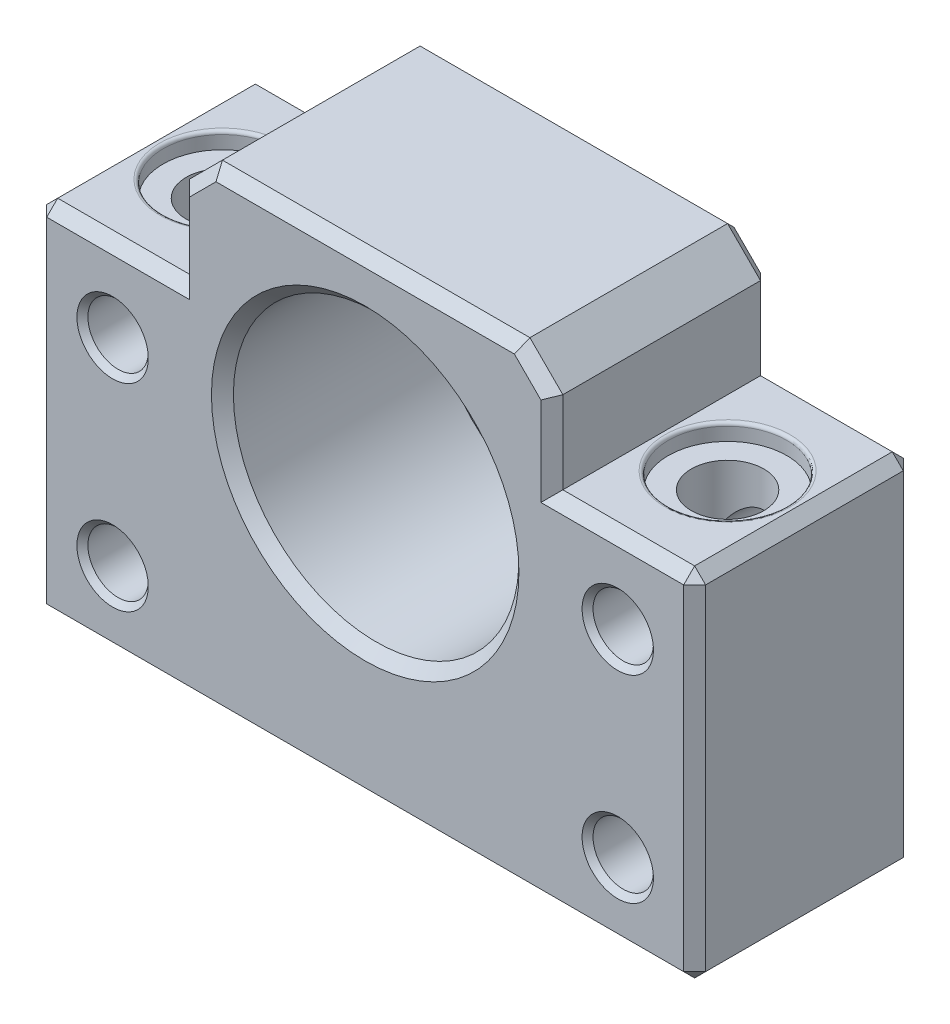
from build123d import *

# Parameters (mm, degrees)
SKETCH1_R           = 13
BOSS_EXTRUDE1_DEPTH = 20
CHAMFER1_SIZE       = 3
CHAMFER2_SIZE       = 1
SKETCH2_R           = 2.75
CUT_EXTRUDE1_DEPTH  = 21
CUT_EXTRUDE2_REACH  = 45
SKETCH3_R           = 3.3
SKETCH4_R           = 5.4
CUT_EXTRUDE3_DEPTH  = 1.5
CHAMFER3_SIZE       = 0.5
FILLET1_R           = 0.3


with BuildPart() as part:
    # Sketch1 → Boss-Extrude1 (new body)
    with BuildSketch(Plane.XY):
        Polygon((17, 0), (-17, 0), (-17, -10.5), (-30, -10.5), (-30, -43), (30, -43), (30, -10.5), (17, -10.5), align=None)
        with Locations((0, -18)):
            Circle(SKETCH1_R, mode=Mode.SUBTRACT)
    extrude(amount=BOSS_EXTRUDE1_DEPTH)

    # Chamfer1
    chamfer1_edges = [part.edges().sort_by_distance(p)[0] for p in [
        (-17, 0, 10),
        (17, 0, 10),
    ]]
    chamfer(chamfer1_edges, length=CHAMFER1_SIZE)

    # Chamfer2
    chamfer2_edges = [part.edges().sort_by_distance(p)[0] for p in [
        (23.5, -10.5, 20),
        (30, -26.75, 0),
        (0, -43, 0),
        (17, -6.75, 20),
        (-30, -43, 10),
        (-30, -10.5, 10),
        (30, -10.5, 10),
        (30, -43, 10),
        (-13, -18, 0),
        (-13, -18, 20),
        (-23.5, -10.5, 20),
        (-30, -26.75, 20),
        (0, 0, 0),
        (0, 0, 20),
        (-17, -6.75, 0),
        (-15.5, -1.5, 0),
        (15.5, -1.5, 0),
        (-17, -6.75, 20),
        (-15.5, -1.5, 20),
        (15.5, -1.5, 20),
        (0, -43, 20),
        (30, -26.75, 20),
        (-30, -26.75, 0),
        (-23.5, -10.5, 0),
        (17, -6.75, 0),
        (23.5, -10.5, 0),
    ]]
    chamfer(chamfer2_edges, length=CHAMFER2_SIZE)

    # Sketch2 → Cut-Extrude1 (cut, through all)
    with BuildSketch(Plane(origin=(0, 0, 0), x_dir=(-1, 0, 0), z_dir=(0, 0, -1))):
        with Locations((-23, -18)):
            Circle(SKETCH2_R)
        with Locations((23, -18)):
            Circle(SKETCH2_R)
        with Locations((23, -36)):
            Circle(SKETCH2_R)
        with Locations((-23, -36)):
            Circle(SKETCH2_R)
    extrude(amount=-CUT_EXTRUDE1_DEPTH, mode=Mode.SUBTRACT)

    # Sketch3 → Cut-Extrude2 (cut, up to next)
    with BuildSketch(Plane.XZ.offset(43), mode=Mode.PRIVATE) as cut_extrude2_sk1:
        with Locations((23, 10)):
            Circle(SKETCH3_R)
    cut_extrude2_tool1 = extrude(cut_extrude2_sk1.sketch, amount=-CUT_EXTRUDE2_REACH, mode=Mode.PRIVATE) & part.part
    add(cut_extrude2_tool1.solids().sort_by_distance((23, -43, 10))[0], mode=Mode.SUBTRACT)
    # Sketch3 → Cut-Extrude2 (cut, up to next)
    with BuildSketch(Plane.XZ.offset(43), mode=Mode.PRIVATE) as cut_extrude2_sk2:
        with Locations((-23, 10)):
            Circle(SKETCH3_R)
    cut_extrude2_tool2 = extrude(cut_extrude2_sk2.sketch, amount=-CUT_EXTRUDE2_REACH, mode=Mode.PRIVATE) & part.part
    add(cut_extrude2_tool2.solids().sort_by_distance((-23, -43, 10))[0], mode=Mode.SUBTRACT)

    # Sketch4 → Cut-Extrude3 (cut)
    with BuildSketch(Plane(origin=(0, -10.5, 0), x_dir=(1, 0, 0), z_dir=(0, 1, 0))):
        with Locations((23, -10)):
            Circle(SKETCH4_R)
        with Locations((-23, -10)):
            Circle(SKETCH4_R)
    extrude(amount=-CUT_EXTRUDE3_DEPTH, mode=Mode.SUBTRACT)

    # Chamfer3
    chamfer3_edges = [part.edges().sort_by_distance(p)[0] for p in [
        (25.75, -18, 20),
        (25.75, -18, 0),
        (-20.25, -18, 20),
        (-20.25, -18, 0),
        (-20.25, -36, 20),
        (-20.25, -36, 0),
        (25.75, -36, 20),
        (25.75, -36, 0),
        (19.7, -43, 10),
        (-26.3, -43, 10),
    ]]
    chamfer(chamfer3_edges, length=CHAMFER3_SIZE)

    # Fillet1
    fillet1_edges = [part.edges().sort_by_distance(p)[0] for p in [
        (17.6, -10.5, 10),
        (-28.4, -10.5, 10),
    ]]
    fillet(fillet1_edges, radius=FILLET1_R)


solid = part.part
